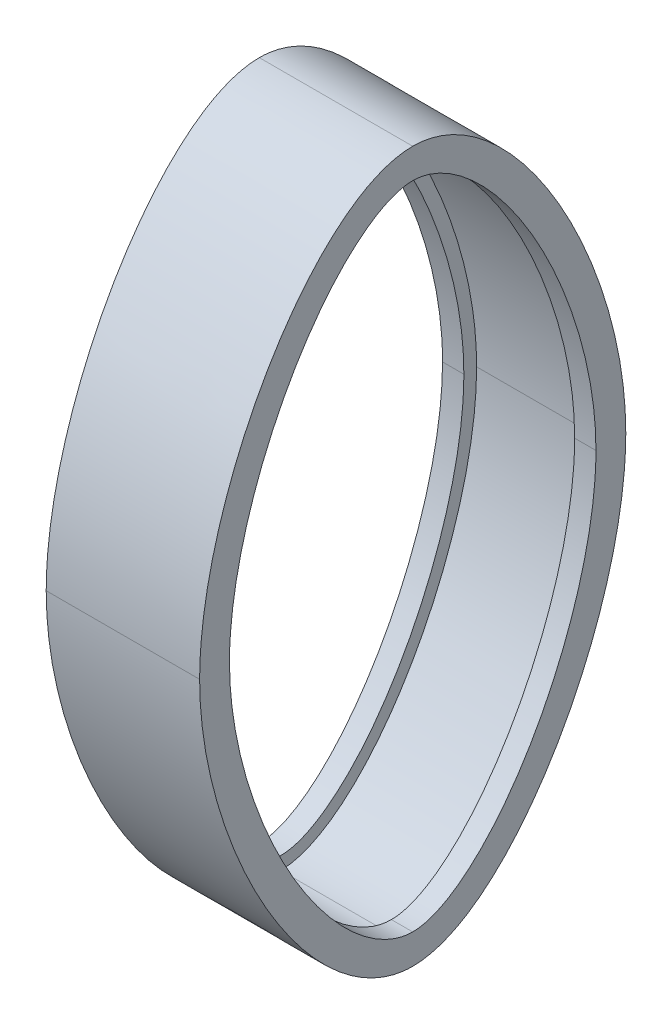
from build123d import *

# Parameters (mm, degrees)
BOSS_EXTRUDE1_DEPTH = 18
CUT_EXTRUDE2_DEPTH  = 5
CUT_EXTRUDE3_DEPTH  = 14.0000001


with BuildPart() as part:
    # Sketch2 → Boss-Extrude1 (new body)
    with BuildSketch(Plane(origin=(104.375329106, 0, 0), x_dir=(0, 0, -1), z_dir=(1, 0, 0))):
        with BuildLine():
            add(Edge.make_bspline(
                [(-367.114153597, -61.099600987), (-367.114153597, -97.766267654), (-340.44748693, -144.432934321), (-317.114153597, -144.432934321)],
                knots=[0, 0, 0, 0, 1, 1, 1, 1], degree=3))
            add(Edge.make_bspline(
                [(-317.114153597, -144.432934321), (-293.780820264, -144.432934321), (-267.114153597, -97.766267654), (-267.114153597, -61.099600987)],
                knots=[0, 0, 0, 0, 1, 1, 1, 1], degree=3))
            add(Edge.make_bspline(
                [(-267.114153597, -61.099600987), (-267.114153597, -24.432934321), (-293.780820264, 22.233732346), (-317.114153597, 22.233732346)],
                knots=[0, 0, 0, 0, 1, 1, 1, 1], degree=3))
            add(Edge.make_bspline(
                [(-317.114153597, 22.233732346), (-340.44748693, 22.233732346), (-367.114153597, -24.432934321), (-367.114153597, -61.099600987)],
                knots=[0, 0, 0, 0, 1, 1, 1, 1], degree=3))
        make_face()
    extrude(amount=BOSS_EXTRUDE1_DEPTH)

    # Sketch4 → Cut-Extrude2 (cut)
    with BuildSketch(Plane(origin=(104.375329106, 0, 0), x_dir=(0, 0, -1), z_dir=(1, 0, 0))):
        with BuildLine():
            add(Edge.make_bspline(
                [(-360.114153597, -61.099600987), (-360.114153597, -63.057577348), (-360.031009885, -64.999065915), (-359.728639914, -68.855057234), (-359.509209501, -70.769519501), (-358.674587125, -76.477938999), (-357.88508445, -80.237329588), (-355.916734507, -87.678901882), (-354.73667737, -91.362117789), (-352.003466774, -98.649425343), (-350.470803155, -102.199571972), (-347.071431043, -109.111765151), (-345.205615658, -112.474314609), (-342.112028738, -117.352101485), (-341.031209578, -118.950087528), (-339.322310509, -121.297699583), (-338.737997323, -122.071970561), (-337.536641419, -123.602082576), (-336.918641864, -124.359061115), (-335.015635894, -126.590439739), (-333.688049104, -128.019846653), (-331.580542998, -130.049284366), (-330.858527549, -130.706494392), (-329.36742291, -131.97442981), (-328.601684654, -132.582166302), (-327.03120016, -133.726698998), (-326.225266682, -134.26474295), (-324.560960462, -135.25409859), (-323.702823868, -135.705800856), (-321.914776134, -136.490493407), (-320.976351927, -136.825152785), (-319.075901017, -137.294090304), (-318.107918584, -137.432934321), (-317.114153597, -137.432934321)],
                knots=[0, 0, 0, 0, 0.0625, 0.0625, 0.125, 0.125, 0.25, 0.25, 0.375, 0.375, 0.5, 0.5, 0.625, 0.625, 0.6875, 0.6875, 0.71875, 0.71875, 0.75, 0.75, 0.8125, 0.8125, 0.84375, 0.84375, 0.875, 0.875, 0.90625, 0.90625, 0.9375, 0.9375, 0.96875, 0.96875, 1, 1, 1, 1], degree=3))
            add(Edge.make_bspline(
                [(-317.114153597, -137.432934321), (-316.122414967, -137.432934321), (-315.158200633, -137.294759433), (-313.740071248, -136.945969695), (-313.272148926, -136.805672828), (-312.344537809, -136.483745911), (-311.885385723, -136.302083744), (-310.540942803, -135.713587706), (-309.679636468, -135.260990109), (-308.007952344, -134.268072754), (-307.197798513, -133.727367239), (-306.013091511, -132.863733171), (-305.622617824, -132.566443357), (-304.855409529, -131.959326705), (-304.478536613, -131.649453785), (-303.365938423, -130.702929875), (-302.648135105, -130.049466231), (-300.554021581, -128.033449098), (-299.236352107, -126.615884522), (-296.719633653, -123.669477047), (-295.521054092, -122.140193784), (-293.223266092, -118.98840684), (-292.135767503, -117.381796779), (-289.0280432, -112.484798623), (-287.160484902, -109.118161021), (-283.764833203, -102.215413936), (-282.237815947, -98.678767208), (-280.198195041, -93.248537218), (-279.559952202, -91.415618152), (-278.373993703, -87.713328497), (-277.829350904, -85.853839922), (-276.345408369, -80.249483918), (-275.553722335, -76.479135689), (-274.718208903, -70.762849067), (-274.498876098, -68.84720609), (-274.196944316, -64.992317399), (-274.114153597, -63.053104782), (-274.114153597, -61.099600987)],
                knots=[0, 0, 0, 0, 0.03125, 0.03125, 0.046875, 0.046875, 0.0625, 0.0625, 0.09375, 0.09375, 0.125, 0.125, 0.140625, 0.140625, 0.15625, 0.15625, 0.1875, 0.1875, 0.25, 0.25, 0.3125, 0.3125, 0.375, 0.375, 0.5, 0.5, 0.625, 0.625, 0.6875, 0.6875, 0.75, 0.75, 0.875, 0.875, 0.9375, 0.9375, 1, 1, 1, 1], degree=3))
            add(Edge.make_bspline(
                [(-274.114153597, -61.099600987), (-274.114153597, -59.141624627), (-274.197297309, -57.200136059), (-274.49966728, -53.34414474), (-274.719097693, -51.429682473), (-275.553720069, -45.721262975), (-276.343222744, -41.961872387), (-278.311572687, -34.520300092), (-279.491629824, -30.837084186), (-282.22484042, -23.549776632), (-283.757504039, -19.999630003), (-287.156876151, -13.087436823), (-289.022691535, -9.724887366), (-292.116278456, -4.84710049), (-293.197097616, -3.249114447), (-294.905996685, -0.901502391), (-295.490309871, -0.127231413), (-296.691665775, 1.402880601), (-297.30966533, 2.159859141), (-299.2126713, 4.391237764), (-300.540258089, 5.820644679), (-302.647764196, 7.850082392), (-303.369779645, 8.507292418), (-304.860884284, 9.775227835), (-305.62662254, 10.382964327), (-307.197107034, 11.527497023), (-308.003040512, 12.065540976), (-309.667346732, 13.054896615), (-310.525483326, 13.506598882), (-312.31353106, 14.291291433), (-313.251955267, 14.625950811), (-315.152406177, 15.094888329), (-316.12038861, 15.233732346), (-317.114153597, 15.233732346)],
                knots=[0, 0, 0, 0, 0.0625, 0.0625, 0.125, 0.125, 0.25, 0.25, 0.375, 0.375, 0.5, 0.5, 0.625, 0.625, 0.6875, 0.6875, 0.71875, 0.71875, 0.75, 0.75, 0.8125, 0.8125, 0.84375, 0.84375, 0.875, 0.875, 0.90625, 0.90625, 0.9375, 0.9375, 0.96875, 0.96875, 1, 1, 1, 1], degree=3))
            add(Edge.make_bspline(
                [(-317.114153597, 15.233732346), (-318.105892227, 15.233732346), (-319.070106561, 15.095557459), (-320.488235946, 14.74676772), (-320.956158268, 14.606470854), (-321.883769385, 14.284543937), (-322.342921471, 14.102881769), (-323.687364391, 13.514385732), (-324.548670726, 13.061788135), (-326.22035485, 12.068870779), (-327.030508681, 11.528165264), (-328.215215683, 10.664531196), (-328.60568937, 10.367241383), (-329.372897665, 9.76012473), (-329.749770581, 9.450251811), (-330.862368771, 8.5037279), (-331.580172089, 7.850264256), (-333.674285613, 5.834247124), (-334.991955087, 4.416682548), (-337.508673541, 1.470275073), (-338.707253102, -0.059008191), (-341.005041102, -3.210795135), (-342.092539691, -4.817405196), (-345.200263993, -9.714403351), (-347.067822292, -13.081040954), (-350.463473991, -19.983788038), (-351.990491246, -23.520434767), (-354.030112153, -28.950664756), (-354.668354992, -30.783583822), (-355.854313491, -34.485873477), (-356.39895629, -36.345362052), (-357.882898825, -41.949718056), (-358.674584859, -45.720066286), (-359.510098291, -51.436352907), (-359.729431096, -53.351995884), (-360.031362878, -57.206884576), (-360.114153597, -59.146097192), (-360.114153597, -61.099600987)],
                knots=[0, 0, 0, 0, 0.03125, 0.03125, 0.046875, 0.046875, 0.0625, 0.0625, 0.09375, 0.09375, 0.125, 0.125, 0.140625, 0.140625, 0.15625, 0.15625, 0.1875, 0.1875, 0.25, 0.25, 0.3125, 0.3125, 0.375, 0.375, 0.5, 0.5, 0.625, 0.625, 0.6875, 0.6875, 0.75, 0.75, 0.875, 0.875, 0.9375, 0.9375, 1, 1, 1, 1], degree=3))
        make_face()
    extrude(amount=CUT_EXTRUDE2_DEPTH, mode=Mode.SUBTRACT)

    # Sketch6 → Cut-Extrude3 (cut, through all)
    with BuildSketch(Plane.ZY.offset(-109.375329106)):
        with BuildLine():
            add(Edge.make_bspline(
                [(317.114153597, -140.432934321), (318.156178658, -140.432934321), (319.177722567, -140.313299876), (320.686208599, -139.994653461), (321.185033103, -139.865048825), (322.175491794, -139.563839491), (322.666305452, -139.392268787), (324.103639198, -138.831794806), (325.024997704, -138.394889633), (326.812490134, -137.426318036), (327.678450926, -136.894354529), (329.365865527, -135.75405686), (330.187243713, -135.145592935), (331.792514296, -133.864342275), (332.573510984, -133.193608111), (334.844908143, -131.120972763), (336.272547149, -129.653028899), (338.316152133, -127.353755252), (338.982000984, -126.569364511), (340.276663285, -124.979949932), (340.905629901, -124.174906659), (342.743464091, -121.732161552), (343.90359163, -120.067027701), (347.220139569, -114.979416206), (349.214930324, -111.465969663), (352.845000083, -104.236735057), (354.479165016, -100.520319969), (356.299264229, -95.749512773), (356.651834719, -94.789381399), (357.330557103, -92.866596073), (357.657195172, -91.902690775), (358.598777331, -89.00340485), (359.17550427, -87.060476882), (360.747339777, -81.200422041), (361.586647815, -77.252526791), (362.472929879, -71.257084945), (362.705703488, -69.24623111), (363.026214955, -65.195880953), (363.114153597, -63.156424282), (363.114153597, -61.099600987)],
                knots=[0, 0, 0, 0, 0.03125, 0.03125, 0.046875, 0.046875, 0.0625, 0.0625, 0.09375, 0.09375, 0.125, 0.125, 0.15625, 0.15625, 0.1875, 0.1875, 0.25, 0.25, 0.28125, 0.28125, 0.3125, 0.3125, 0.375, 0.375, 0.5, 0.5, 0.625, 0.625, 0.65625, 0.65625, 0.6875, 0.6875, 0.75, 0.75, 0.875, 0.875, 0.9375, 0.9375, 1, 1, 1, 1], degree=3))
            add(Edge.make_bspline(
                [(363.114153597, -61.099600987), (363.114153597, -59.050455013), (363.026807009, -57.013115516), (362.706295375, -52.958146533), (362.47295833, -50.940540296), (361.878478191, -46.922603129), (361.517249331, -44.922283793), (360.888107504, -41.933604769), (360.663799099, -40.939351134), (360.186964702, -38.954657984), (359.934156026, -37.963268644), (358.607771345, -33.038627216), (357.346379233, -29.186264965), (354.461043271, -21.639661726), (352.837046853, -17.945443666), (349.209062191, -10.722735029), (347.206666606, -7.193549841), (343.850475003, -2.053552254), (342.681146248, -0.380119174), (340.230898127, 2.868214746), (338.949534858, 4.444350388), (336.248448491, 7.478454917), (334.829353217, 8.936959998), (332.560954943, 11.005359002), (331.778528867, 11.676808416), (330.175306898, 12.955404507), (329.353838335, 13.563559516), (327.663116833, 14.70492834), (326.793955784, 15.238286268), (325.445050079, 15.967491348), (324.987845343, 16.198688309), (324.055981997, 16.63370897), (323.579369242, 16.838230019), (322.1392362, 17.396003541), (321.163277376, 17.695685273), (319.171625301, 18.114361772), (318.156014694, 18.233732346), (317.114153597, 18.233732346)],
                knots=[0, 0, 0, 0, 0.0625, 0.0625, 0.125, 0.125, 0.1875, 0.1875, 0.21875, 0.21875, 0.25, 0.25, 0.375, 0.375, 0.5, 0.5, 0.625, 0.625, 0.6875, 0.6875, 0.75, 0.75, 0.8125, 0.8125, 0.84375, 0.84375, 0.875, 0.875, 0.90625, 0.90625, 0.921875, 0.921875, 0.9375, 0.9375, 0.96875, 0.96875, 1, 1, 1, 1], degree=3))
            add(Edge.make_bspline(
                [(317.114153597, 18.233732346), (316.072128536, 18.233732346), (315.050584627, 18.114097902), (313.542098595, 17.795451487), (313.043274091, 17.665846851), (312.052815399, 17.364637517), (311.562001742, 17.193066813), (310.124667996, 16.632592832), (309.20330949, 16.195687659), (307.415817059, 15.227116062), (306.549856268, 14.695152554), (304.862441667, 13.554854885), (304.041063481, 12.946390961), (302.435792898, 11.6651403), (301.65479621, 10.994406137), (299.383399051, 8.921770788), (297.955760045, 7.453826924), (295.912155061, 5.154553278), (295.24630621, 4.370162536), (293.951643909, 2.780747958), (293.322677293, 1.975704684), (291.484843102, -0.467040422), (290.324715564, -2.132174273), (287.008167625, -7.219785768), (285.01337687, -10.733232312), (281.383307111, -17.962466917), (279.749142178, -21.678882005), (277.929042964, -26.449689202), (277.576472475, -27.409820576), (276.897750091, -29.332605901), (276.571112022, -30.296511199), (275.629529863, -33.195797124), (275.052802924, -35.138725093), (273.480967417, -40.998779933), (272.641659379, -44.946675183), (271.755377315, -50.94211703), (271.522603706, -52.952970864), (271.202092239, -57.003321022), (271.114153597, -59.042777692), (271.114153597, -61.099600987)],
                knots=[0, 0, 0, 0, 0.03125, 0.03125, 0.046875, 0.046875, 0.0625, 0.0625, 0.09375, 0.09375, 0.125, 0.125, 0.15625, 0.15625, 0.1875, 0.1875, 0.25, 0.25, 0.28125, 0.28125, 0.3125, 0.3125, 0.375, 0.375, 0.5, 0.5, 0.625, 0.625, 0.65625, 0.65625, 0.6875, 0.6875, 0.75, 0.75, 0.875, 0.875, 0.9375, 0.9375, 1, 1, 1, 1], degree=3))
            add(Edge.make_bspline(
                [(271.114153597, -61.099600987), (271.114153597, -63.148746961), (271.201500185, -65.186086458), (271.522011819, -69.241055442), (271.755348864, -71.258661678), (272.349829003, -75.276598845), (272.711057863, -77.276918182), (273.34019969, -80.265597205), (273.564508094, -81.25985084), (274.041342491, -83.24454399), (274.294151168, -84.23593333), (275.620535848, -89.160574758), (276.881927961, -93.012937009), (279.767263923, -100.559540248), (281.391260341, -104.253758309), (285.019245003, -111.476466945), (287.021640588, -115.005652134), (290.377832191, -120.145649721), (291.547160946, -121.8190828), (293.997409067, -125.06741672), (295.278772336, -126.643552363), (297.979858703, -129.677656891), (299.398953977, -131.136161972), (301.667352251, -133.204560976), (302.449778327, -133.87601039), (304.053000296, -135.154606482), (304.874468859, -135.76276149), (306.56519036, -136.904130314), (307.43435141, -137.437488242), (308.783257115, -138.166693322), (309.240461851, -138.397890284), (310.172325197, -138.832910944), (310.648937952, -139.037431994), (312.089070994, -139.595205515), (313.065029818, -139.894887247), (315.056681893, -140.313563747), (316.0722925, -140.432934321), (317.114153597, -140.432934321)],
                knots=[0, 0, 0, 0, 0.0625, 0.0625, 0.125, 0.125, 0.1875, 0.1875, 0.21875, 0.21875, 0.25, 0.25, 0.375, 0.375, 0.5, 0.5, 0.625, 0.625, 0.6875, 0.6875, 0.75, 0.75, 0.8125, 0.8125, 0.84375, 0.84375, 0.875, 0.875, 0.90625, 0.90625, 0.921875, 0.921875, 0.9375, 0.9375, 0.96875, 0.96875, 1, 1, 1, 1], degree=3))
        make_face()
    extrude(amount=-CUT_EXTRUDE3_DEPTH, mode=Mode.SUBTRACT)

    # Mirror1: part across plane


with BuildPart() as part_1:
    add(part.part)
    add(part.part.mirror(Plane(origin=(122.375329106, 0, 0), x_dir=(0, 0, 1), z_dir=(1, 0, 0))))


solid = part_1.part
